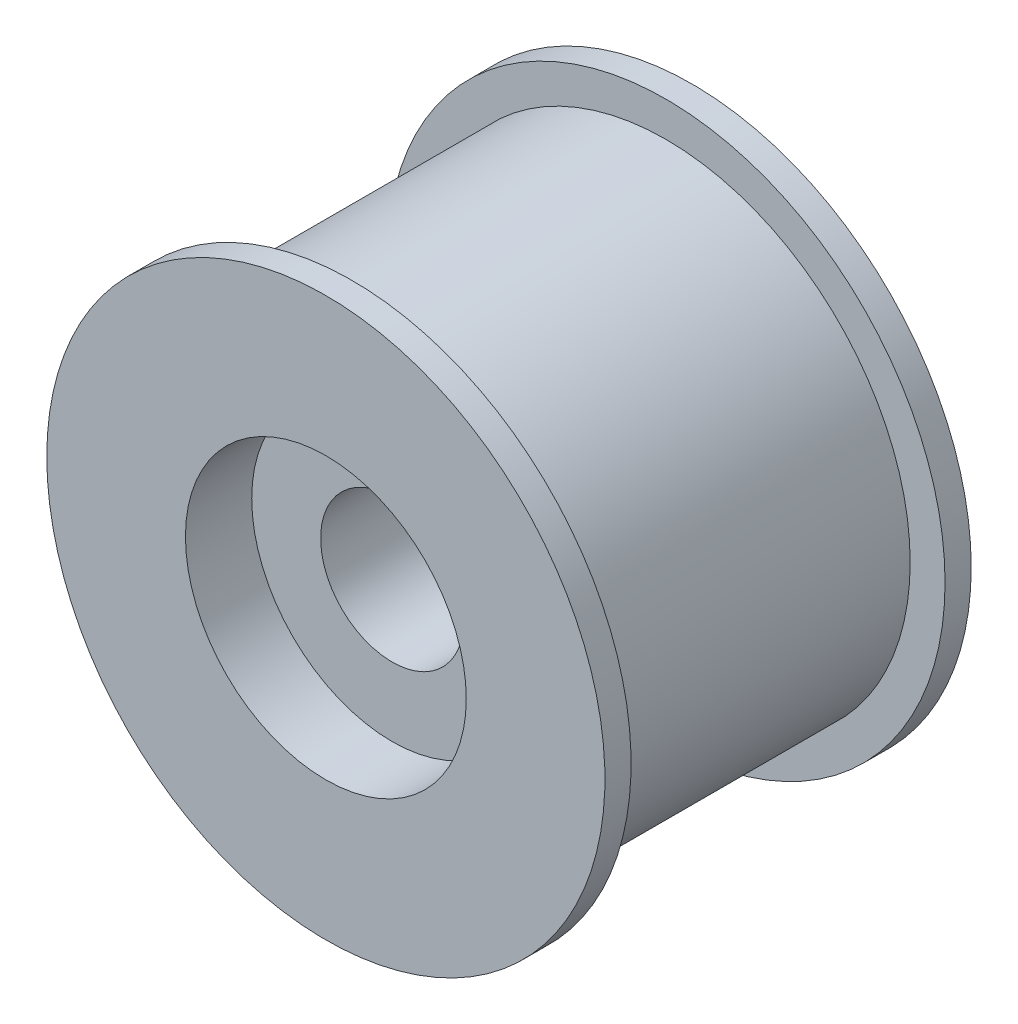
from build123d import *

# Parameters (mm, degrees)
SKETCH1_R           = 14
SKETCH1_R_2         = 4.1
BOSS_EXTRUDE1_DEPTH = 21
SKETCH8_R           = 16
SKETCH8_R_2         = 6.25
BOSS_EXTRUDE2_DEPTH = 1.5
SKETCH9_R           = 16
SKETCH9_R_2         = 6.25
BOSS_EXTRUDE3_DEPTH = 1.5
SKETCH10_R          = 8.05
CUT_EXTRUDE1_DEPTH  = 3.8
CUT_EXTRUDE2_START  = -21
SKETCH10_2_R        = 8.05
CUT_EXTRUDE2_DEPTH  = 3.8


with BuildPart() as part:
    # Sketch1 → Boss-Extrude1 (new body)
    with BuildSketch(Plane.XY):
        Circle(SKETCH1_R)
        Circle(SKETCH1_R_2, mode=Mode.SUBTRACT)
    extrude(amount=BOSS_EXTRUDE1_DEPTH)

    # Sketch8 → Boss-Extrude2 (add)
    with BuildSketch(Plane(origin=(0, 0, 21), x_dir=(-1, 0, 0), z_dir=(0, 0, -1))):
        Circle(SKETCH8_R)
        Circle(SKETCH8_R_2, mode=Mode.SUBTRACT)
    extrude(amount=BOSS_EXTRUDE2_DEPTH)

    # Sketch9 → Boss-Extrude3 (add)
    with BuildSketch(Plane.XY):
        Circle(SKETCH9_R)
        Circle(SKETCH9_R_2, mode=Mode.SUBTRACT)
    extrude(amount=BOSS_EXTRUDE3_DEPTH)

    # Sketch10 → Cut-Extrude1 (cut)
    with BuildSketch(Plane.XY.offset(21)):
        Circle(SKETCH10_R)
    extrude(amount=-CUT_EXTRUDE1_DEPTH, mode=Mode.SUBTRACT)

    # Sketch10_2 → Cut-Extrude2 (cut)
    with BuildSketch(Plane.XY.offset(21).offset(CUT_EXTRUDE2_START)):
        Circle(SKETCH10_2_R)
    extrude(amount=CUT_EXTRUDE2_DEPTH, mode=Mode.SUBTRACT)


solid = part.part
